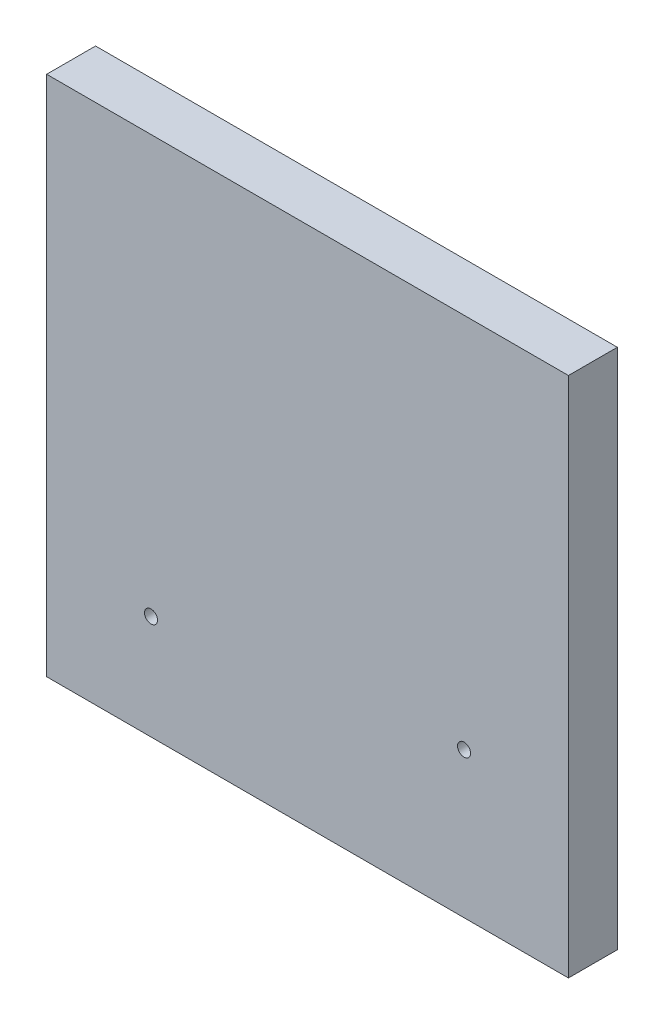
from build123d import *

# Parameters (mm, degrees)
SKETCH1_W           = 127
SKETCH1_H           = 127
SKETCH1_R           = 1.5875
BOSS_EXTRUDE1_DEPTH = 11.90625


with BuildPart() as part:
    # Sketch1 → Boss-Extrude1 (new body)
    with BuildSketch(Plane.XY):
        with Locations((63.5, 63.5)):
            Rectangle(SKETCH1_W, SKETCH1_H)
        with Locations((25.4, 25.4)):
            Circle(SKETCH1_R, mode=Mode.SUBTRACT)
        with Locations((101.6, 35.433)):
            Circle(SKETCH1_R, mode=Mode.SUBTRACT)
    extrude(amount=BOSS_EXTRUDE1_DEPTH)


solid = part.part
